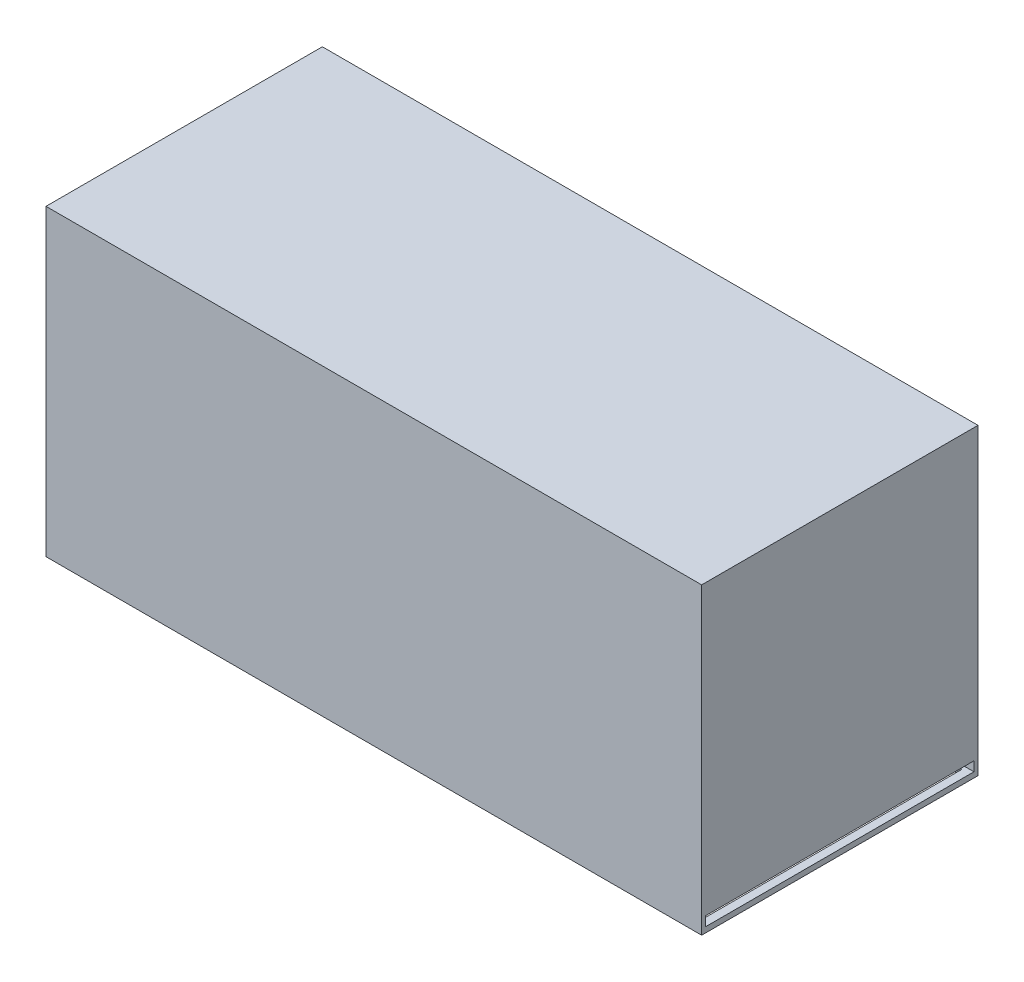
from build123d import *

# Parameters (mm, degrees)
SCHIZZO1_W                   = 121
SCHIZZO1_H                   = 56
ESTRUSIONE_ESTRUSIONE4_DEPTH = 51
SCHIZZO6_W                   = 118
SCHIZZO6_H                   = 48
TAGLIO_ESTRUSIONE2_DEPTH     = 53
SCHIZZO7_W                   = 22
SCHIZZO7_H                   = 28
ESTRUSIONE_ESTRUSIONE5_DEPTH = 48
SCHIZZO13_W                  = 20
SCHIZZO13_H                  = 26
TAGLIO_ESTRUSIONE3_DEPTH     = 48
SCHIZZO15_W                  = 118
SCHIZZO15_H                  = 1
ESTRUSIONE_ESTRUSIONE6_DEPTH = 2
SCHIZZO16_W                  = 3
SCHIZZO16_H                  = 1
ESTRUSIONE_ESTRUSIONE7_DEPTH = 48
SCHIZZO17_W                  = 49.5
SCHIZZO17_H                  = 1.75
TAGLIO_ESTRUSIONE4_DEPTH     = 120


with BuildPart() as part:
    # Schizzo1 → Estrusione-Estrusione4 (new body)
    with BuildSketch(Plane.XY):
        with Locations((60.5, 28)):
            Rectangle(SCHIZZO1_W, SCHIZZO1_H)
    extrude(amount=ESTRUSIONE_ESTRUSIONE4_DEPTH)

    # Schizzo6 → Taglio-Estrusione2 (cut)
    with BuildSketch(Plane.XZ):
        with Locations((60.5, 25.5)):
            Rectangle(SCHIZZO6_W, SCHIZZO6_H)
    extrude(amount=-TAGLIO_ESTRUSIONE2_DEPTH, mode=Mode.SUBTRACT)

    # Schizzo7 → Estrusione-Estrusione5 (add)
    with BuildSketch(Plane.XZ.offset(-53)):
        with Locations((12.5, 35.5)):
            Rectangle(SCHIZZO7_W, SCHIZZO7_H)
    extrude(amount=ESTRUSIONE_ESTRUSIONE5_DEPTH)

    # Schizzo13 → Taglio-Estrusione3 (cut)
    with BuildSketch(Plane.XZ.offset(-5)):
        with Locations((12.5, 35.5)):
            Rectangle(SCHIZZO13_W, SCHIZZO13_H)
    extrude(amount=-TAGLIO_ESTRUSIONE3_DEPTH, mode=Mode.SUBTRACT)

    # Schizzo15 → Estrusione-Estrusione6 (add)
    with BuildSketch(Plane.XZ.offset(-53)):
        with Locations((60.5, 7)):
            Rectangle(SCHIZZO15_W, SCHIZZO15_H)
    extrude(amount=ESTRUSIONE_ESTRUSIONE6_DEPTH)

    # Schizzo16 → Estrusione-Estrusione7 (add)
    with BuildSketch(Plane.XZ.offset(-51)):
        with Locations((118, 7)):
            Rectangle(SCHIZZO16_W, SCHIZZO16_H)
    extrude(amount=ESTRUSIONE_ESTRUSIONE7_DEPTH)

    # Schizzo17 → Taglio-Estrusione4 (cut)
    with BuildSketch(Plane(origin=(121, 0, 0), x_dir=(0, 0, -1), z_dir=(1, 0, 0))):
        with Locations((-25.5, 1.875)):
            Rectangle(SCHIZZO17_W, SCHIZZO17_H)
    extrude(amount=-TAGLIO_ESTRUSIONE4_DEPTH, mode=Mode.SUBTRACT)


solid = part.part
